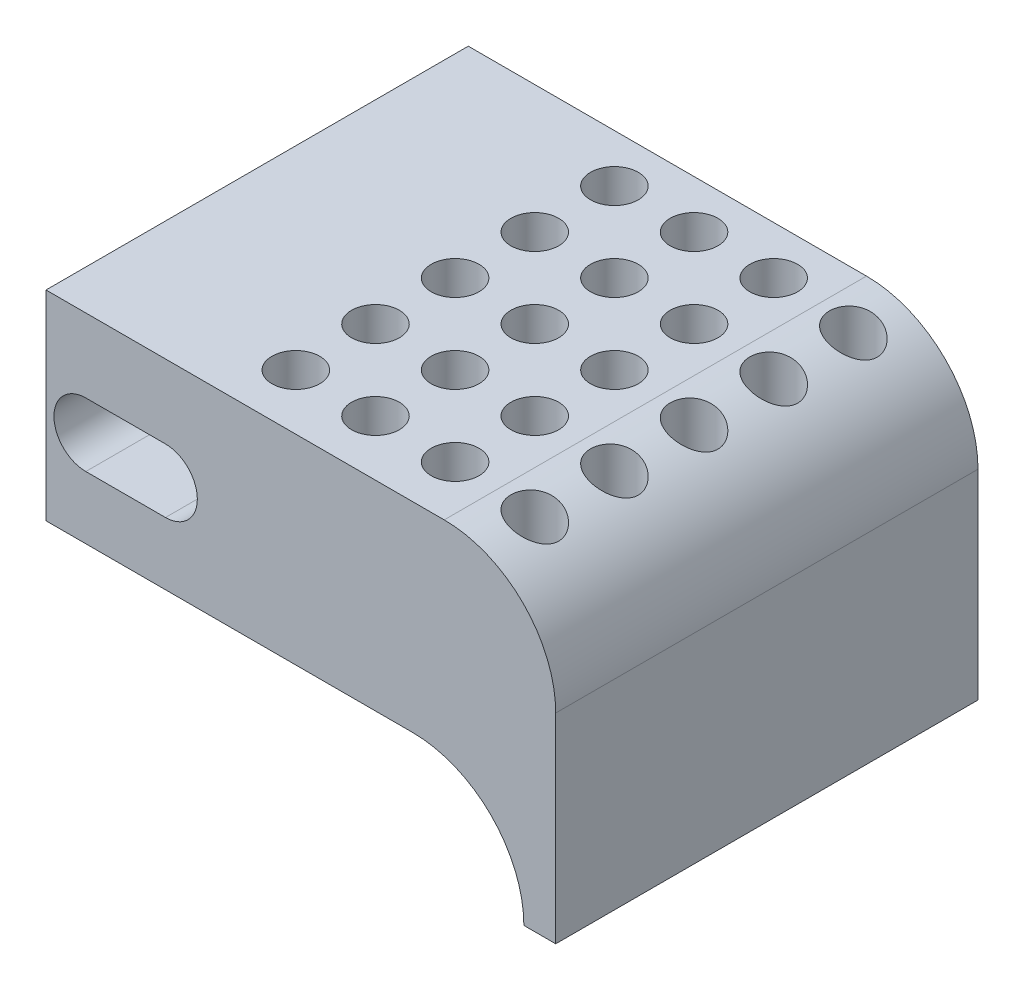
from build123d import *

# Parameters (mm, degrees)
BOSS_EXTRU_1_DEPTH           = 26.51
CONG_1_R                     = 7
ESQUISSE2_R                  = 1.5
ENL_V_MAT_EXTRU_2_DEPTH      = 10
ENL_V_MAT_EXTRU_2_DEPTH_BACK = 20


with BuildPart() as part:
    # Esquisse1 → Boss.-Extru.1 (new body)
    with BuildSketch(Plane.XY):
        with BuildLine():
            Line((0, 0), (23, 0))
            ThreePointArc((23, 0), (27.949747468, -2.050252532), (30, -7))
            Line((30, -7), (32, -7))
            Line((32, -7), (32, -2.95))
            Line((32, -2.95), (32, 12.55))
            Line((32, 12.55), (0, 12.55))
            Line((0, 12.55), (0, 0))
        make_face()
        with BuildLine():
            Line((2.5, 7.929296875), (7.5, 7.929296875))
            ThreePointArc((7.5, 7.929296875), (9.5, 5.929296875), (7.5, 3.929296875))
            Line((7.5, 3.929296875), (2.5, 3.929296875))
            ThreePointArc((2.5, 3.929296875), (0.5, 5.929296875), (2.5, 7.929296875))
        make_face(mode=Mode.SUBTRACT)
    extrude(amount=BOSS_EXTRU_1_DEPTH)

    # Congé1
    cong_1_edges = [part.edges().sort_by_distance(p)[0] for p in [
        (32, 12.55, 13.255),
    ]]
    fillet(cong_1_edges, radius=CONG_1_R)

    # Esquisse2 → Enlèv. mat.-Extru.2 (cut, two sides)
    with BuildSketch(Plane.XZ) as enl_v_mat_extru_2_sk:
        with Locations(Location((12.193732445, 3.01943583, 0), (0, 0, 90))):
            Circle(ESQUISSE2_R)
        with Locations(Location((17.193732445, 3.01943583, 0), (0, 0, 90))):
            Circle(ESQUISSE2_R)
        with Locations(Location((22.193732445, 3.01943583, 0), (0, 0, 57.485590174))):
            Circle(ESQUISSE2_R)
        with Locations(Location((17.193732445, 8.01943583, 0), (0, 0, 90))):
            Circle(ESQUISSE2_R)
        with Locations(Location((22.193732445, 8.01943583, 0), (0, 0, 57.485590174))):
            Circle(ESQUISSE2_R)
        with Locations(Location((17.193732445, 13.01943583, 0), (0, 0, 90))):
            Circle(ESQUISSE2_R)
        with Locations(Location((22.193732445, 13.01943583, 0), (0, 0, 57.485590174))):
            Circle(ESQUISSE2_R)
        with Locations(Location((17.193732445, 18.01943583, 0), (0, 0, 90))):
            Circle(ESQUISSE2_R)
        with Locations(Location((22.193732445, 18.01943583, 0), (0, 0, 57.485590174))):
            Circle(ESQUISSE2_R)
        with Locations(Location((17.193732445, 23.01943583, 0), (0, 0, 90))):
            Circle(ESQUISSE2_R)
        with Locations(Location((22.193732445, 23.01943583, 0), (0, 0, 57.485590174))):
            Circle(ESQUISSE2_R)
        with Locations(Location((12.193732445, 8.01943583, 0), (0, 0, 90))):
            Circle(ESQUISSE2_R)
        with Locations(Location((12.193732445, 13.01943583, 0), (0, 0, 90))):
            Circle(ESQUISSE2_R)
        with Locations(Location((12.193732445, 18.01943583, 0), (0, 0, 90))):
            Circle(ESQUISSE2_R)
        with Locations(Location((12.193732445, 23.01943583, 0), (0, 0, 90))):
            Circle(ESQUISSE2_R)
        with Locations(Location((27.193732445, 3.01943583, 0), (0, 0, 90))):
            Circle(ESQUISSE2_R)
        with Locations(Location((27.193732445, 8.01943583, 0), (0, 0, 90))):
            Circle(ESQUISSE2_R)
        with Locations(Location((27.193732445, 13.01943583, 0), (0, 0, 90))):
            Circle(ESQUISSE2_R)
        with Locations(Location((27.193732445, 18.01943583, 0), (0, 0, 90))):
            Circle(ESQUISSE2_R)
        with Locations(Location((27.193732445, 23.01943583, 0), (0, 0, 90))):
            Circle(ESQUISSE2_R)
    extrude(amount=ENL_V_MAT_EXTRU_2_DEPTH, mode=Mode.SUBTRACT)
    extrude(enl_v_mat_extru_2_sk.sketch, amount=-ENL_V_MAT_EXTRU_2_DEPTH_BACK, mode=Mode.SUBTRACT)


solid = part.part
